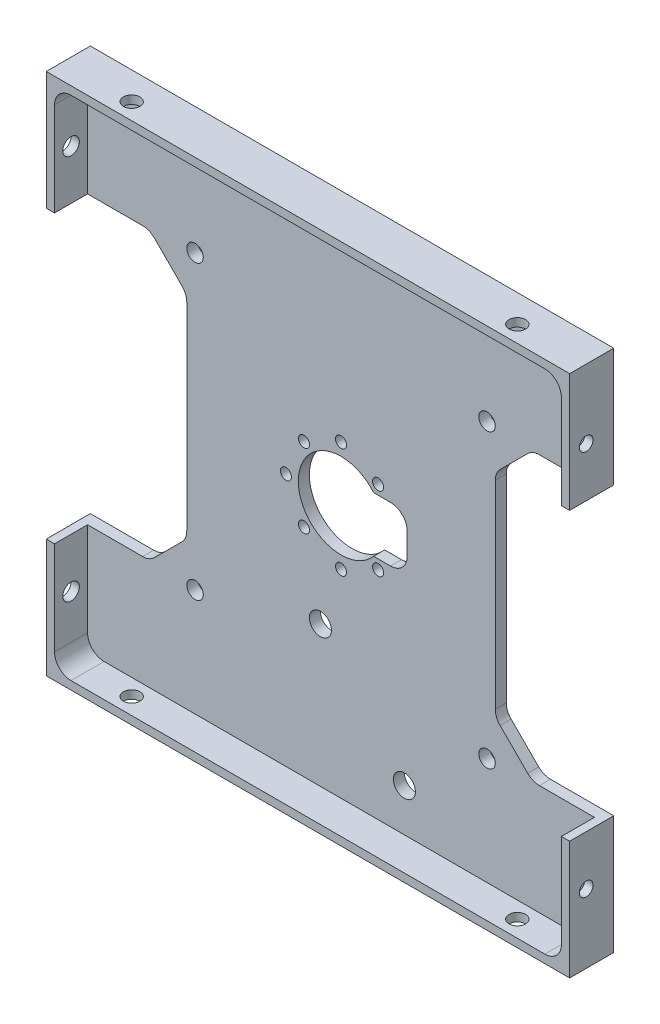
from build123d import *

# Parameters (mm, degrees)
SKETCH1_W                 = 96
SKETCH1_H                 = 96
BOSS_EXTRUDE1_DEPTH       = 8
SKETCH2_W                 = 92
SKETCH2_H                 = 92
COMPONENT_PLATFORM_DEPTH  = 6
CABLE_SLOTS_DEPTH         = 6
SKETCH4_R                 = 7.75
CENTER_MASS_CUT_DEPTH     = 6
INNER_CORNER_FILLETS_R    = 3
SKETCH10_W                = 12
SKETCH10_H                = 10
MOTOR_CUTOUT_DEPTH        = 2
FILLET1_R                 = 3
M3X0_5_TAPPED_HOLE1_D     = 2.5
M3X0_5_TAPPED_HOLE1_DEPTH = 2
F_3_0MM_DOWEL_HOLE1_D     = 3
F_3_0MM_DOWEL_HOLE1_DEPTH = 2
F_3_0MM_DOWEL_HOLE2_D     = 3
F_3_0MM_DOWEL_HOLE2_DEPTH = 2
F_2_0MM_DOWEL_HOLE1_D     = 2
F_2_0MM_DOWEL_HOLE1_DEPTH = 2
F_4_0MM_DOWEL_HOLE1_D     = 4
F_4_0MM_DOWEL_HOLE1_DEPTH = 2
F_3_0MM_DOWEL_HOLE3_D     = 3
F_3_0MM_DOWEL_HOLE3_DEPTH = 2
SKETCH34_OUTSIDE_W        = 125.2
SKETCH34_OUTSIDE_H        = 125.2
SKETCH34_OUTSIDE_W_2      = 95
SKETCH34_OUTSIDE_H_2      = 95
CUT_EXTRUDE1_DEPTH        = 10


with BuildPart() as part:
    # Sketch1 → Boss-Extrude1 (new body)
    with BuildSketch(Plane.XY):
        Rectangle(SKETCH1_W, SKETCH1_H)
    extrude(amount=BOSS_EXTRUDE1_DEPTH)

    # Sketch2 → Component Platform (cut)
    with BuildSketch(Plane.XY.offset(8)):
        Rectangle(SKETCH2_W, SKETCH2_H)
    extrude(amount=-COMPONENT_PLATFORM_DEPTH, mode=Mode.SUBTRACT)

    # Sketch3 → Cable Slots (cut, symmetric)
    with BuildSketch(Plane.XY.offset(2)):
        with BuildLine():
            Line((-33.878679656, -25.121320344), (-28.878679656, -20.121320344))
            ThreePointArc((-28.878679656, -20.121320344), (-28.228361402, -19.148050297), (-28, -18))
            Line((-28, -18), (-28, 18))
            ThreePointArc((-28, 18), (-28.228361402, 19.148050297), (-28.878679656, 20.121320344))
            Line((-28.878679656, 20.121320344), (-33.878679656, 25.121320344))
            ThreePointArc((-33.878679656, 25.121320344), (-34.851949703, 25.771638598), (-36, 26))
            Line((-36, 26), (-48, 26))
            Line((-48, 26), (-48, -26))
            Line((-48, -26), (-36, -26))
            ThreePointArc((-36, -26), (-34.851949703, -25.771638598), (-33.878679656, -25.121320344))
        make_face()
        with BuildLine():
            Line((48, -26), (48, 26))
            Line((48, 26), (36, 26))
            ThreePointArc((36, 26), (34.851949703, 25.771638598), (33.878679656, 25.121320344))
            Line((33.878679656, 25.121320344), (28.878679656, 20.121320344))
            ThreePointArc((28.878679656, 20.121320344), (28.228361402, 19.148050297), (28, 18))
            Line((28, 18), (28, -18))
            ThreePointArc((28, -18), (28.228361402, -19.148050297), (28.878679656, -20.121320344))
            Line((28.878679656, -20.121320344), (33.878679656, -25.121320344))
            ThreePointArc((33.878679656, -25.121320344), (34.851949703, -25.771638598), (36, -26))
            Line((36, -26), (48, -26))
        make_face()
    extrude(amount=CABLE_SLOTS_DEPTH, both=True, mode=Mode.SUBTRACT)

    # Sketch4 → Center Mass Cut (cut)
    with BuildSketch(Plane.XY.offset(2)):
        Circle(SKETCH4_R)
    extrude(amount=-CENTER_MASS_CUT_DEPTH, mode=Mode.SUBTRACT)

    # Inner Corner Fillets
    inner_corner_fillets_edges = [part.edges().sort_by_distance(p)[0] for p in [
        (-46, -46, 5),
        (-46, 46, 5),
        (46, 46, 5),
        (46, -46, 5),
    ]]
    fillet(inner_corner_fillets_edges, radius=INNER_CORNER_FILLETS_R)

    # Sketch10 → Motor Cutout (cut)
    with BuildSketch(Plane.XY.offset(2)):
        with Locations((6, 0)):
            Rectangle(SKETCH10_W, SKETCH10_H)
    extrude(amount=-MOTOR_CUTOUT_DEPTH, mode=Mode.SUBTRACT)

    # Fillet1
    fillet1_edges = [part.edges().sort_by_distance(p)[0] for p in [
        (12, -5, 1),
        (12, 5, 1),
    ]]
    fillet(fillet1_edges, radius=FILLET1_R)

    # M3x0.5 Tapped Hole1
    with Locations(Plane(origin=(48, 0, 0), x_dir=(0, 0, -1), z_dir=(1, 0, 0))):
        with Locations((-5, -35), (-5, 35)):
            Hole(M3X0_5_TAPPED_HOLE1_D / 2, depth=M3X0_5_TAPPED_HOLE1_DEPTH)

    # Ø3.0mm Dowel Hole1
    with Locations(Plane(origin=(0, 48, 0), x_dir=(1, 0, 0), z_dir=(0, 1, 0))):
        with Locations((35, -5), (-35, -5)):
            f_3_0mm_dowel_hole1 = Hole(F_3_0MM_DOWEL_HOLE1_D / 2, depth=F_3_0MM_DOWEL_HOLE1_DEPTH)

    # Mirror2: Ø3.0mm Dowel Hole1 across plane
    add(f_3_0mm_dowel_hole1.mirror(Plane(origin=(0, 0, 0), x_dir=(0, 0, 1), z_dir=(0, -1, 0))), mode=Mode.SUBTRACT)

    # Ø3.0mm Dowel Hole2
    with Locations(Plane.XY.offset(2)):
        with Locations((-26.5, -26.5), (26.5, -26.5), (26.5, 26.5), (-26.5, 26.5)):
            Hole(F_3_0MM_DOWEL_HOLE2_D / 2, depth=F_3_0MM_DOWEL_HOLE2_DEPTH)

    # Ø2.0mm Dowel Hole1
    with Locations(Plane.XY.offset(2)):
        with Locations((6.72, -6.72), (0, -10), (-6.72, -6.72), (-10, 0), (-6.72, 6.72), (0, 10), (6.72, 6.72)):
            Hole(F_2_0MM_DOWEL_HOLE1_D / 2, depth=F_2_0MM_DOWEL_HOLE1_DEPTH)

    # Ø4.0mm Dowel Hole1
    with Locations(Plane.XY.offset(2)):
        with Locations((-3.74, -20.47), (11.5, -38.25)):
            Hole(F_4_0MM_DOWEL_HOLE1_D / 2, depth=F_4_0MM_DOWEL_HOLE1_DEPTH)

    # Ø3.0mm Dowel Hole3
    with Locations(Plane(origin=(-48, 35, 5), x_dir=(0, 0, -1), z_dir=(-1, 0, 0))):
        with Locations((0, 0), (0, 70)):
            Hole(F_3_0MM_DOWEL_HOLE3_D / 2, depth=F_3_0MM_DOWEL_HOLE3_DEPTH)

    # Sketch34 outside → Cut-Extrude1 (cut)
    with BuildSketch(Plane(origin=(0, 0, 0), x_dir=(-1, 0, 0), z_dir=(0, 0, -1))):
        Rectangle(SKETCH34_OUTSIDE_W, SKETCH34_OUTSIDE_H)
        Rectangle(SKETCH34_OUTSIDE_W_2, SKETCH34_OUTSIDE_H_2, mode=Mode.SUBTRACT)
    extrude(amount=-CUT_EXTRUDE1_DEPTH, mode=Mode.SUBTRACT)


solid = part.part
